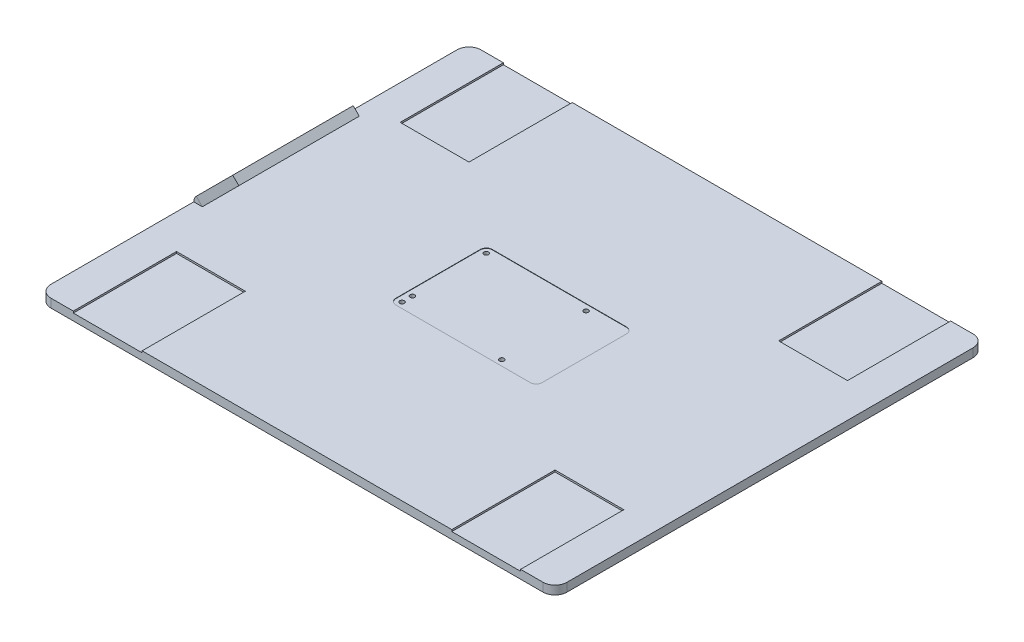
from build123d import *

# Parameters (mm, degrees)
BOSS_EXTRUDE1_DEPTH      = 5
SKETCH1_3_R              = 1.35
BOSS_EXTRUDE2_DEPTH      = 4.8
SKETCH1_4_W              = 40
SKETCH1_4_H              = 60
BOSS_EXTRUDE3_DEPTH      = 4
SKETCH3_W                = 5
SKETCH3_H                = 15
REVOLVE3_ANGLE           = 45
REVOLVE3_OTHER_WAY_ANGLE = 45
SKETCH6_W                = 70
SKETCH6_H                = 5
BOSS_EXTRUDE6_DEPTH      = 30
SKETCH7_R                = 1.1
CUT_EXTRUDE1_DEPTH       = 0.2
SKETCH7_8_R              = 1.1
CUT_EXTRUDE2_DEPTH       = 6


with BuildPart() as part:
    # Sketch1 → Boss-Extrude1 (new body)
    with BuildSketch(Plane(origin=(0, 0, 0), x_dir=(1, 0, 0), z_dir=(0, 1, 0))):
        with BuildLine():
            Line((20, 0), (7, 0))
            ThreePointArc((7, 0), (2.050252532, -2.050252532), (0, -7))
            Line((0, -7), (0, -243))
            ThreePointArc((0, -243), (2.050252532, -247.949747468), (7, -250))
            Line((7, -250), (20, -250))
            Line((20, -250), (20, -190))
            Line((20, -190), (60, -190))
            Line((60, -190), (60, -250))
            Line((60, -250), (240, -250))
            Line((240, -250), (240, -190))
            Line((240, -190), (280, -190))
            Line((280, -190), (280, -250))
            Line((280, -250), (293, -250))
            ThreePointArc((293, -250), (297.949747468, -247.949747468), (300, -243))
            Line((300, -243), (300, -7))
            ThreePointArc((300, -7), (297.949747468, -2.050252532), (293, 0))
            Line((293, 0), (280, 0))
            Line((280, 0), (280, -60))
            Line((280, -60), (240, -60))
            Line((240, -60), (240, 0))
            Line((240, 0), (60, 0))
            Line((60, 0), (60, -60))
            Line((60, -60), (20, -60))
            Line((20, -60), (20, 0))
        make_face()
        with BuildLine():
            ThreePointArc((107.272783739, -100.70753353), (108.297910005, -98.232659796), (110.772783739, -97.20753353))
            Line((110.772783739, -97.20753353), (188.772783739, -97.20753353))
            ThreePointArc((188.772783739, -97.20753353), (191.247657473, -98.232659796), (192.272783739, -100.70753353))
            Line((192.272783739, -100.70753353), (192.272783739, -149.70753353))
            ThreePointArc((192.272783739, -149.70753353), (191.247657473, -152.182407265), (188.772783739, -153.20753353))
            Line((188.772783739, -153.20753353), (110.772783739, -153.20753353))
            ThreePointArc((110.772783739, -153.20753353), (108.297910005, -152.182407265), (107.272783739, -149.70753353))
            Line((107.272783739, -149.70753353), (107.272783739, -100.70753353))
        make_face(mode=Mode.SUBTRACT)
    extrude(amount=BOSS_EXTRUDE1_DEPTH)

    # Sketch1_3 → Boss-Extrude2 (add)
    with BuildSketch(Plane(origin=(0, 0, 0), x_dir=(1, 0, 0), z_dir=(0, 1, 0))):
        with BuildLine():
            Line((188.772783739, -97.20753353), (110.772783739, -97.20753353))
            ThreePointArc((110.772783739, -97.20753353), (108.297910005, -98.232659796), (107.272783739, -100.70753353))
            Line((107.272783739, -100.70753353), (107.272783739, -149.70753353))
            ThreePointArc((107.272783739, -149.70753353), (108.297910005, -152.182407265), (110.772783739, -153.20753353))
            Line((110.772783739, -153.20753353), (188.772783739, -153.20753353))
            ThreePointArc((188.772783739, -153.20753353), (191.247657473, -152.182407265), (192.272783739, -149.70753353))
            Line((192.272783739, -149.70753353), (192.272783739, -100.70753353))
            ThreePointArc((192.272783739, -100.70753353), (191.247657473, -98.232659796), (188.772783739, -97.20753353))
        make_face()
        with Locations((110.772783739, -149.70753353)):
            Circle(SKETCH1_3_R, mode=Mode.SUBTRACT)
        with Locations((110.772783739, -143.70753353)):
            Circle(SKETCH1_3_R, mode=Mode.SUBTRACT)
        with Locations((168.772783739, -149.70753353)):
            Circle(SKETCH1_3_R, mode=Mode.SUBTRACT)
        with Locations((110.772783739, -100.70753353)):
            Circle(SKETCH1_3_R, mode=Mode.SUBTRACT)
        with Locations((168.772783739, -100.70753353)):
            Circle(SKETCH1_3_R, mode=Mode.SUBTRACT)
    extrude(amount=BOSS_EXTRUDE2_DEPTH)

    # Sketch1_4 → Boss-Extrude3 (add)
    with BuildSketch(Plane(origin=(0, 0, 0), x_dir=(1, 0, 0), z_dir=(0, 1, 0))):
        with Locations((40, -30)):
            Rectangle(SKETCH1_4_W, SKETCH1_4_H)
        with Locations((260, -30)):
            Rectangle(SKETCH1_4_W, SKETCH1_4_H)
        with Locations((40, -220)):
            Rectangle(SKETCH1_4_W, SKETCH1_4_H)
        with Locations((260, -220)):
            Rectangle(SKETCH1_4_W, SKETCH1_4_H)
    extrude(amount=BOSS_EXTRUDE3_DEPTH)

    # Sketch3 → Revolve3 (revolve)
    with BuildSketch(Plane(origin=(0, 5, 0), x_dir=(1, 0, 0), z_dir=(0, 1, 0))):
        with Locations((2.5, -97.5)):
            Rectangle(SKETCH3_W, SKETCH3_H)
        with Locations((2.5, -152.5)):
            Rectangle(SKETCH3_W, SKETCH3_H)
    revolve(axis=Axis((5, 5, 105), (0, 0, -1)), revolution_arc=REVOLVE3_ANGLE)

    # Sketch3 → Revolve3 other way (revolve)
    with BuildSketch(Plane(origin=(0, 5, 0), x_dir=(1, 0, 0), z_dir=(0, 1, 0))):
        with Locations((2.5, -97.5)):
            Rectangle(SKETCH3_W, SKETCH3_H)
        with Locations((2.5, -152.5)):
            Rectangle(SKETCH3_W, SKETCH3_H)
    revolve(axis=Axis((5, 5, 105), (0, 0, 1)), revolution_arc=REVOLVE3_OTHER_WAY_ANGLE)


with BuildPart() as body_2:
    # Sketch6 → Boss-Extrude6 (new body)
    with BuildSketch(Plane(origin=(5, 5, 0), x_dir=(0, 0, -1), z_dir=(0.7071067811865487, 0.7071067811865465, 0))):
        with Locations((-125, 2.5)):
            Rectangle(SKETCH6_W, SKETCH6_H)
    extrude(amount=BOSS_EXTRUDE6_DEPTH)

    # Sketch7 → Cut-Extrude1 (cut)
    with BuildSketch(Plane(origin=(-3.535533906, 3.535533906, 0), x_dir=(0, 0, 1), z_dir=(-0.7071067811865465, 0.7071067811865486, 0))):
        with BuildLine():
            Line((115.5, 10.071067812), (135.5, 10.071067812))
            ThreePointArc((135.5, 10.071067812), (137.267766953, 10.803300859), (138, 12.571067812))
            Line((138, 12.571067812), (138, 31.571067812))
            ThreePointArc((138, 31.571067812), (137.267766953, 33.338834765), (135.5, 34.071067812))
            Line((135.5, 34.071067812), (115.5, 34.071067812))
            ThreePointArc((115.5, 34.071067812), (113.732233047, 33.338834765), (113, 31.571067812))
            Line((113, 31.571067812), (113, 12.571067812))
            ThreePointArc((113, 12.571067812), (113.732233047, 10.803300859), (115.5, 10.071067812))
        make_face()
        with Locations((115.5, 31.571067812)):
            Circle(SKETCH7_R, mode=Mode.SUBTRACT)
        with Locations((135.5, 31.571067812)):
            Circle(SKETCH7_R, mode=Mode.SUBTRACT)
        with Locations((115.5, 12.571067812)):
            Circle(SKETCH7_R, mode=Mode.SUBTRACT)
        with Locations((135.5, 12.571067812)):
            Circle(SKETCH7_R, mode=Mode.SUBTRACT)
    extrude(amount=-CUT_EXTRUDE1_DEPTH, mode=Mode.SUBTRACT)

    # Sketch7_8 → Cut-Extrude2 (cut)
    with BuildSketch(Plane(origin=(-3.535533906, 3.535533906, 0), x_dir=(0, 0, 1), z_dir=(-0.7071067811865465, 0.7071067811865486, 0))):
        with Locations((115.5, 31.571067812)):
            Circle(SKETCH7_8_R)
        with Locations((135.5, 31.571067812)):
            Circle(SKETCH7_8_R)
        with Locations((115.5, 12.571067812)):
            Circle(SKETCH7_8_R)
        with Locations((135.5, 12.571067812)):
            Circle(SKETCH7_8_R)
    extrude(amount=-CUT_EXTRUDE2_DEPTH, mode=Mode.SUBTRACT)


solid = Compound([part.part, body_2.part])
